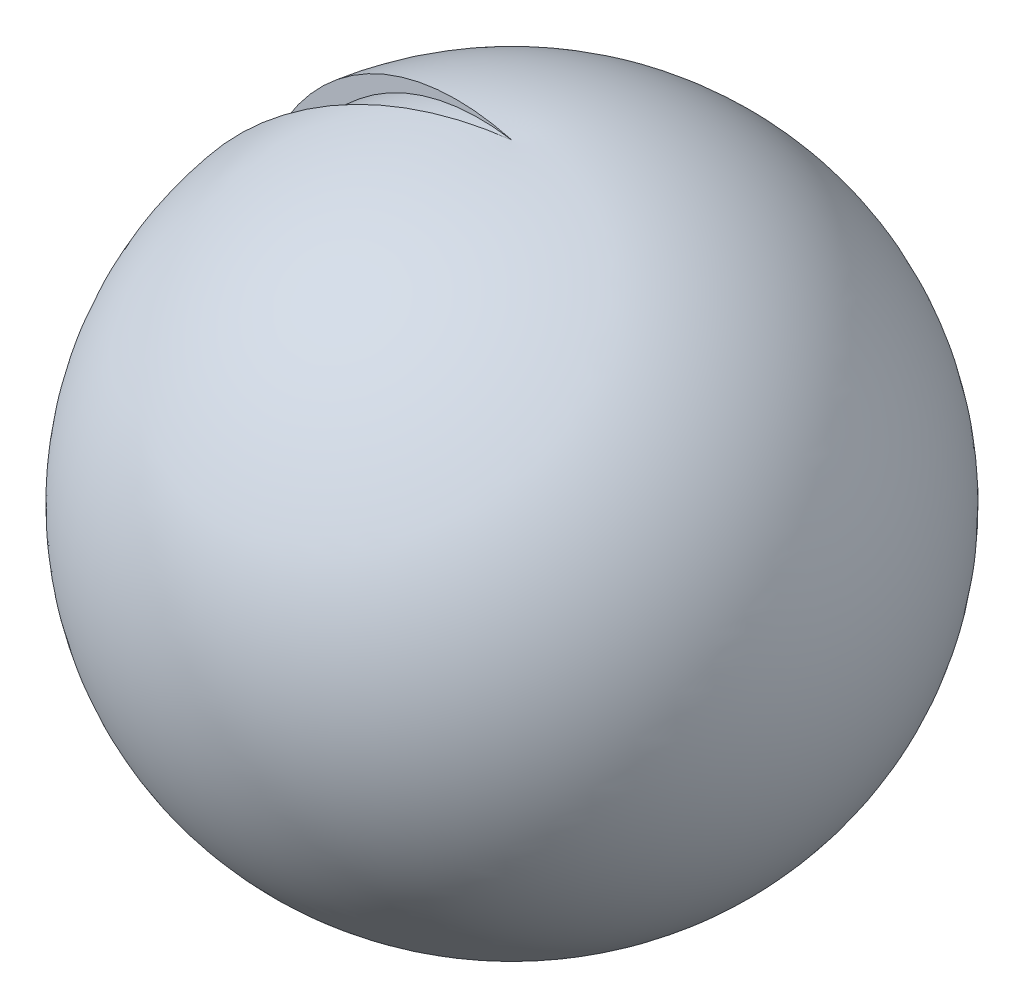
from build123d import *

# Parameters (mm, degrees)
REVOLVE1_ANGLE = 340
REVOLVE2_ANGLE = 20


with BuildPart() as part:
    # Model → Revolve1 (revolve, symmetric)
    with BuildSketch(Plane.XY) as revolve1_sk:
        with BuildLine():
            Line((140.544184358, 151.503354377), (140.544184358, -461.613769335))
            ThreePointArc((140.544184358, -461.613769335), (351.013576899, -486.047632913), (548.655856868, -409.680702543))
            ThreePointArc((548.655856868, -409.680702543), (879.541793961, 602.43871601), (0, 1202.66988269))
            Line((0, 1202.66988269), (0, 756.23238923))
            ThreePointArc((0, 756.23238923), (58.200098626, 637.227966476), (78.504931639, 506.31953332))
            ThreePointArc((78.504931639, 506.31953332), (230.544730993, 350.071699615), (140.544184358, 151.503354377))
        make_face()
    revolve(axis=Axis((0, 756.23238923, 0), (0, 1, 0)), revolution_arc=REVOLVE1_ANGLE / 2)
    revolve(revolve1_sk.sketch, axis=Axis((0, 756.23238923, 0), (0, -1, 0)), revolution_arc=REVOLVE1_ANGLE / 2)


with BuildPart() as body_2:
    # Sketch2 → Revolve2 (revolve, symmetric)
    with BuildSketch(Plane.XY) as revolve2_sk:
        with BuildLine():
            Line((0, 756.23238923), (0, 1202.66988269))
            ThreePointArc((0, 1202.66988269), (-453.237543186, 1053.748570646), (-763.727993223, 691.536604846))
            ThreePointArc((-763.727993223, 691.536604846), (-754.853800421, 300.147200555), (-438.550300515, 69.460154893))
            ThreePointArc((-438.550300515, 69.460154893), (-448.200671236, 544.40686722), (-78.167232247, 842.304103253))
            ThreePointArc((-78.167232247, 842.304103253), (-36.23989999, 801.850806865), (0, 756.23238923))
        make_face()
    revolve(axis=Axis((0, 756.23238923, 0), (0, 1, 0)), revolution_arc=REVOLVE2_ANGLE / 2)
    revolve(revolve2_sk.sketch, axis=Axis((0, 756.23238923, 0), (0, -1, 0)), revolution_arc=REVOLVE2_ANGLE / 2)


solid = Compound([part.part, body_2.part])
